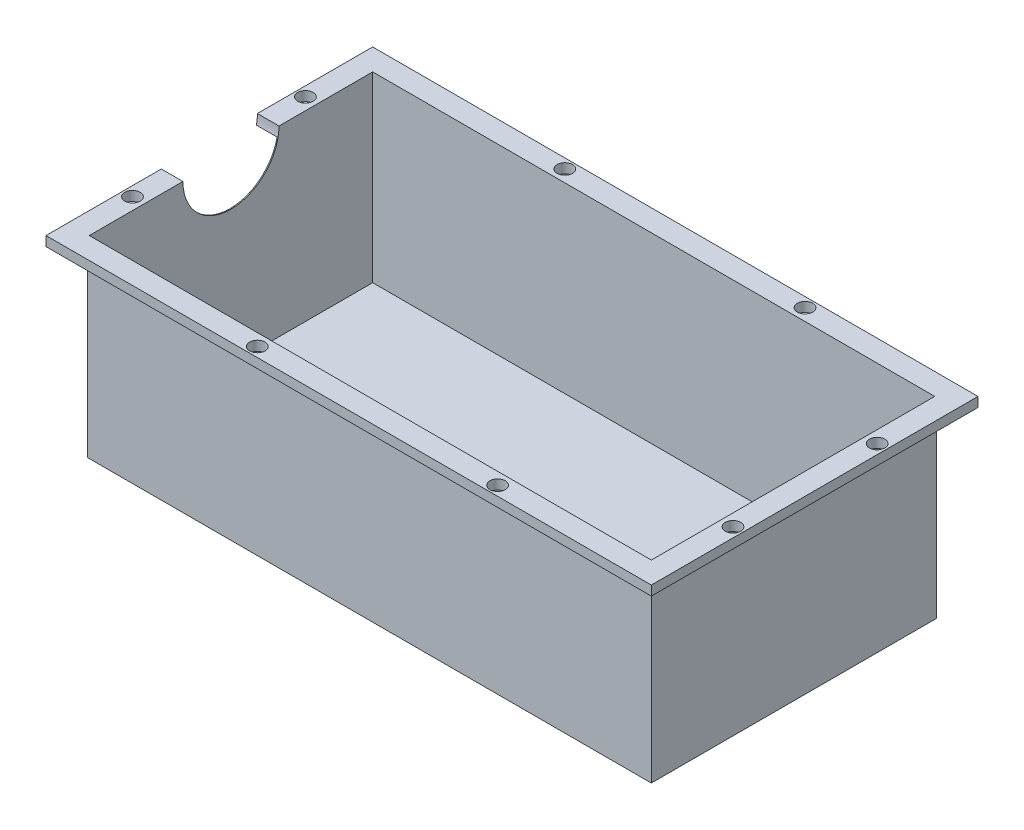
from build123d import *

# Parameters (mm, degrees)
SKETCH1_W           = 126
SKETCH1_H           = 68
BOSS_EXTRUDE1_DEPTH = 40
SKETCH2_W           = 117
SKETCH2_H           = 59
CUT_EXTRUDE1_DEPTH  = 38
SKETCH3_W           = 126
SKETCH3_H           = 68
SKETCH3_W_2         = 117.4
SKETCH3_H_2         = 59.4
CUT_EXTRUDE2_DEPTH  = 38
SKETCH4_R           = 10
CUT_EXTRUDE3_DEPTH  = 38
SKETCH6_R           = 1.6
CUT_EXTRUDE4_DEPTH  = 41


with BuildPart() as part:
    # Sketch1 → Boss-Extrude1 (new body)
    with BuildSketch(Plane(origin=(0, 0, 0), x_dir=(1, 0, 0), z_dir=(0, 1, 0))):
        Rectangle(SKETCH1_W, SKETCH1_H)
    extrude(amount=BOSS_EXTRUDE1_DEPTH)

    # Sketch2 → Cut-Extrude1 (cut)
    with BuildSketch(Plane(origin=(0, 40, 0), x_dir=(1, 0, 0), z_dir=(0, 1, 0))):
        Rectangle(SKETCH2_W, SKETCH2_H)
    extrude(amount=-CUT_EXTRUDE1_DEPTH, mode=Mode.SUBTRACT)

    # Sketch3 → Cut-Extrude2 (cut)
    with BuildSketch(Plane.XZ):
        Rectangle(SKETCH3_W, SKETCH3_H)
        Rectangle(SKETCH3_W_2, SKETCH3_H_2, mode=Mode.SUBTRACT)
    extrude(amount=-CUT_EXTRUDE2_DEPTH, mode=Mode.SUBTRACT)

    # Sketch4 → Cut-Extrude3 (cut)
    with BuildSketch(Plane.ZY.offset(63)):
        with Locations((0, 40)):
            Circle(SKETCH4_R)
    extrude(amount=-CUT_EXTRUDE3_DEPTH, mode=Mode.SUBTRACT)

    # Sketch6 → Cut-Extrude4 (cut, through all)
    with BuildSketch(Plane.XZ):
        with Locations((61, 15)):
            Circle(SKETCH6_R)
        with Locations((-61, 18)):
            Circle(SKETCH6_R)
        with Locations((-61, -18)):
            Circle(SKETCH6_R)
        with Locations((61, -15)):
            Circle(SKETCH6_R)
        with Locations((-21, 32)):
            Circle(SKETCH6_R)
        with Locations((-21, -32)):
            Circle(SKETCH6_R)
        with Locations((29, 32)):
            Circle(SKETCH6_R)
        with Locations((29, -32)):
            Circle(SKETCH6_R)
    extrude(amount=-CUT_EXTRUDE4_DEPTH, mode=Mode.SUBTRACT)


solid = part.part
